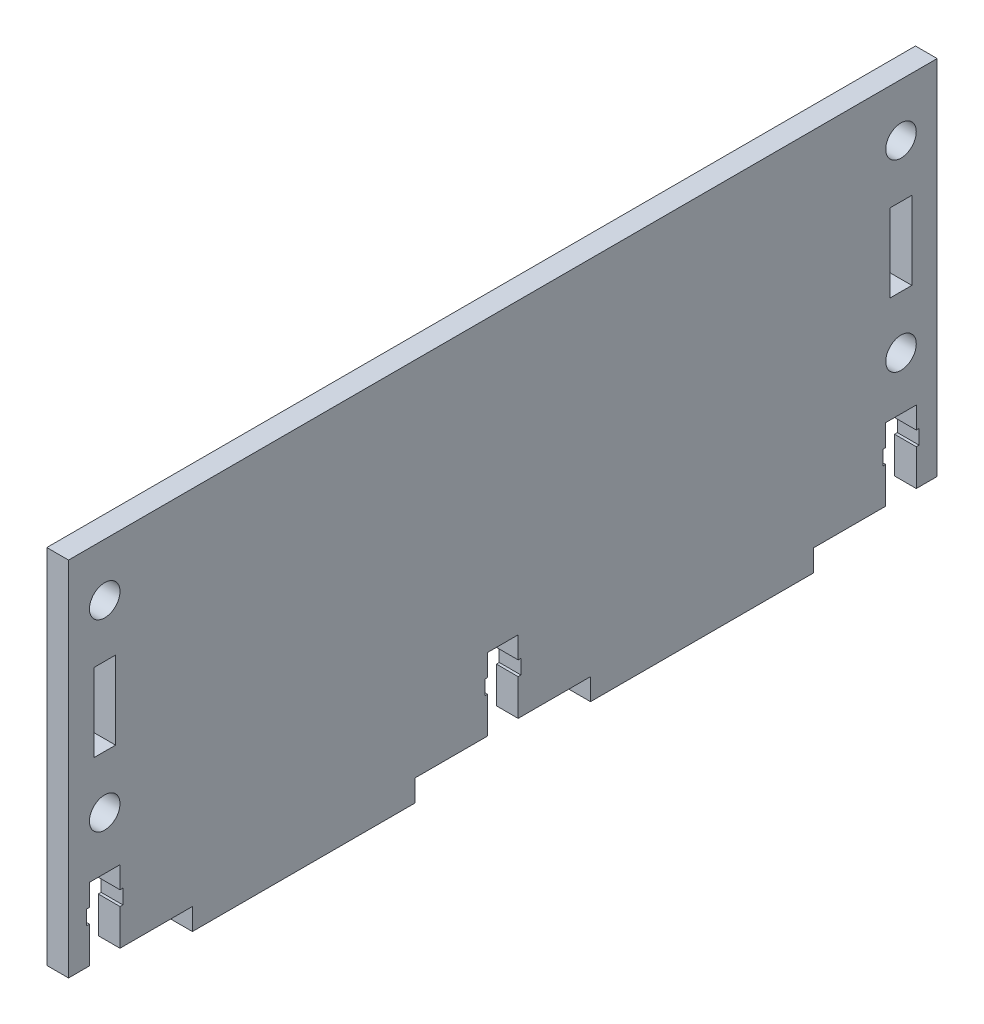
from build123d import *

# Parameters (mm, degrees)
SKETCH2_W                      = 3
SKETCH2_H                      = 10.78
BOSS_EXTRUDE2_DEPTH            = 3
HOLE_FOR_M3_300_SC_NUTS_SP_1_D = 4.22


with BuildPart() as part:
    # Sketch2 → Boss-Extrude2 (new body)
    with BuildSketch(Plane(origin=(0, 0, 0), x_dir=(0, 0, -1), z_dir=(1, 0, 0))):
        Polygon((0, 0), (2.89, 0), (2.89, 5), (2.5, 5), (2.5, 7), (2.89, 7), (2.89, 10), (7.11, 10), (7.11, 7), (7.5, 7), (7.5, 5), (7.11, 5), (7.11, 0), (17.11, 0), (17.11, -3), (47.89, -3), (47.89, 0), (57.89, 0), (57.89, 5), (57.5, 5), (57.5, 7), (57.89, 7), (57.89, 10), (62.11, 10), (62.11, 7), (62.5, 7), (62.5, 5), (62.11, 5), (62.11, 0), (72.11, 0), (72.11, -3), (102.89, -3), (102.89, 0), (112.89, 0), (112.89, 5), (112.5, 5), (112.5, 7), (112.89, 7), (112.89, 10), (117.11, 10), (117.11, 7), (117.5, 7), (117.5, 5), (117.11, 5), (117.11, 0), (120, 0), (120, 50), (0, 50), align=None)
        with Locations((115, 30)):
            Rectangle(SKETCH2_W, SKETCH2_H, mode=Mode.SUBTRACT)
        with Locations((5, 30)):
            Rectangle(SKETCH2_W, SKETCH2_H, mode=Mode.SUBTRACT)
    extrude(amount=BOSS_EXTRUDE2_DEPTH)

    # Hole for M3 300® SC Nuts (SP)1 (through all)
    with Locations(Plane(origin=(3, 0, 0), x_dir=(0, 0, -1), z_dir=(1, 0, 0))):
        with Locations((5, 42.695), (5, 17.305), (115, 42.695), (115, 17.305)):
            Hole(HOLE_FOR_M3_300_SC_NUTS_SP_1_D / 2)


solid = part.part
